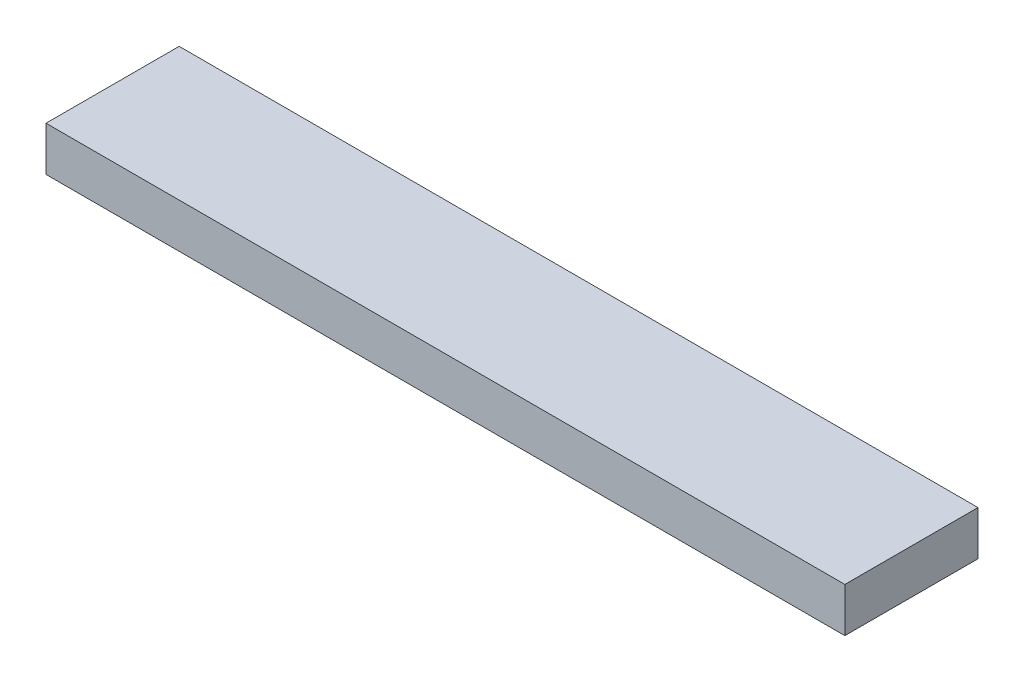
from build123d import *

# Parameters (mm, degrees)
SKETCH1_W           = 180
SKETCH1_H           = 30
BOSS_EXTRUDE1_DEPTH = 10


with BuildPart() as part:
    # Sketch1 → Boss-Extrude1 (new body)
    with BuildSketch(Plane(origin=(0, 0, 0), x_dir=(1, 0, 0), z_dir=(0, 1, 0))):
        Rectangle(SKETCH1_W, SKETCH1_H)
    extrude(amount=BOSS_EXTRUDE1_DEPTH)


solid = part.part
